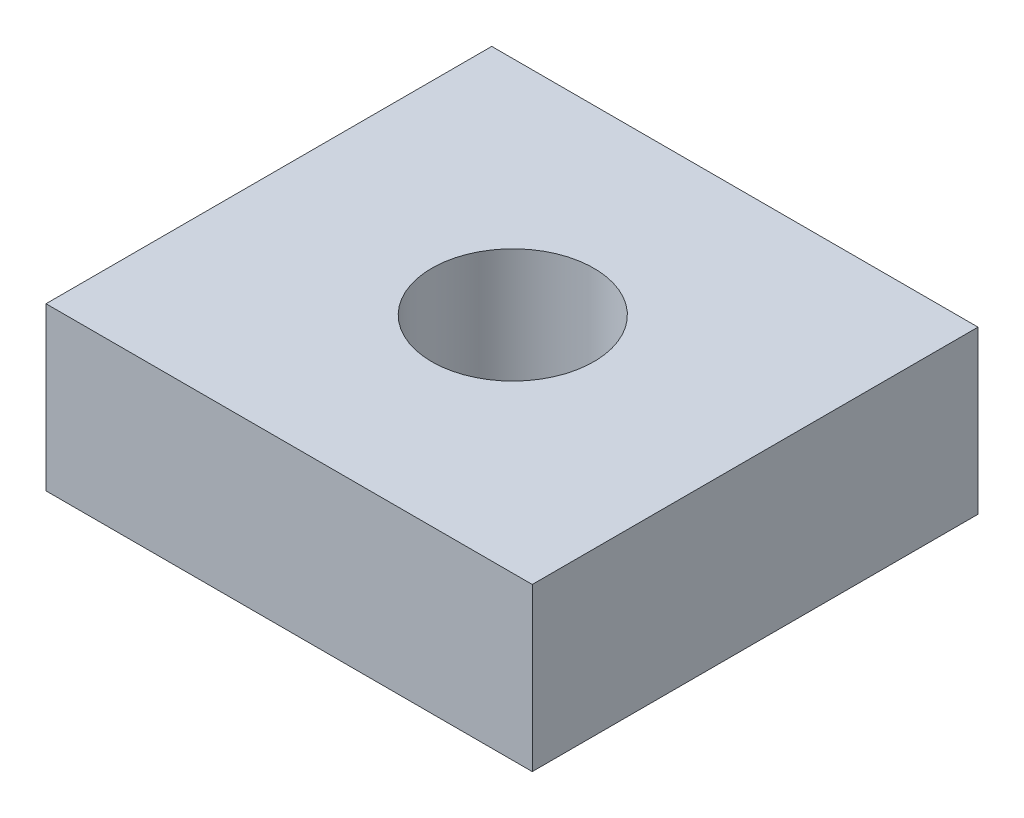
from build123d import *

# Parameters (mm, degrees)
SKETCH1_W           = 76.2
SKETCH1_H           = 69.85
SKETCH1_R           = 12.7
BOSS_EXTRUDE1_DEPTH = 25.4


with BuildPart() as part:
    # Sketch1 → Boss-Extrude1 (new body)
    with BuildSketch(Plane(origin=(0, 0, 0), x_dir=(1, 0, 0), z_dir=(0, 1, 0))):
        with Locations((38.1, 34.925)):
            Rectangle(SKETCH1_W, SKETCH1_H)
        with Locations((38.1, 35.052)):
            Circle(SKETCH1_R, mode=Mode.SUBTRACT)
    extrude(amount=BOSS_EXTRUDE1_DEPTH)


solid = part.part
